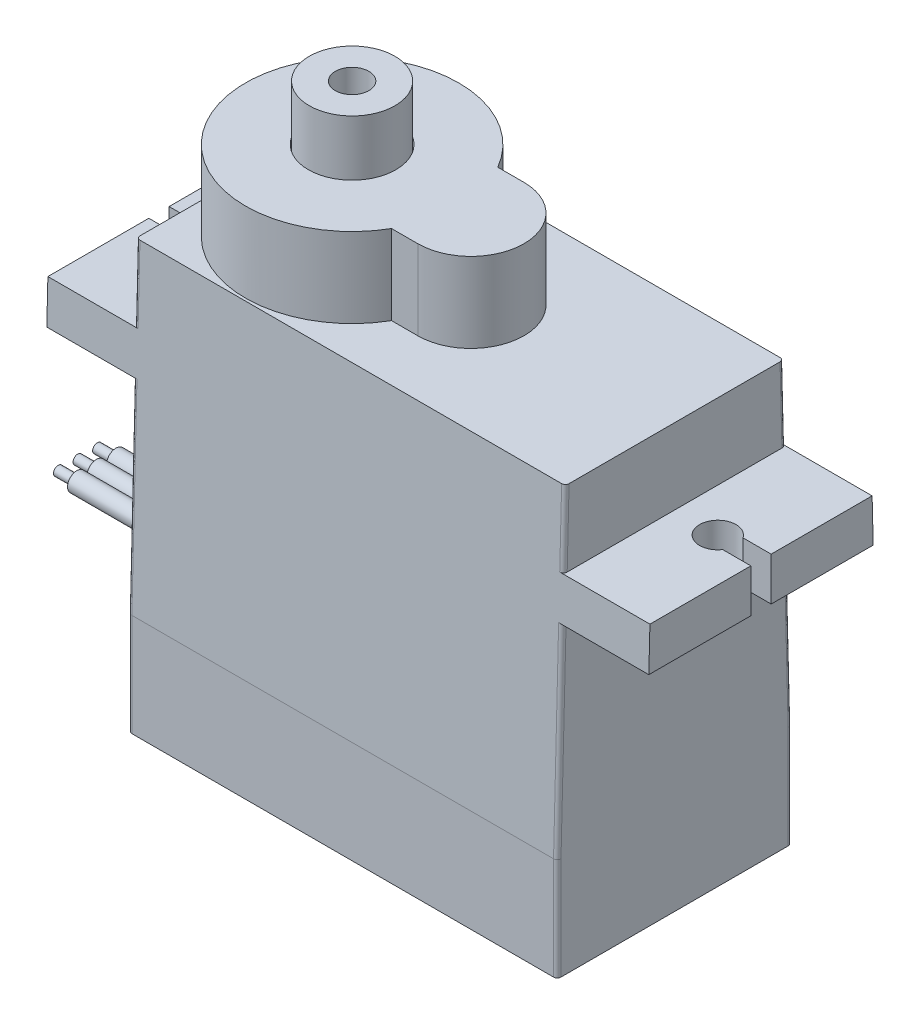
from build123d import *

# Parameters (mm, degrees)
BOSS_EXTRUDE1_DEPTH      = 6.295
BOSS_EXTRUDE2_DEPTH      = 4.28
CUT_EXTRUDE4_DEPTH       = 33.31
SKETCH4_R                = 0.975
SKETCH4_W                = 1.511544683
SKETCH4_H                = 1.09
CUT_EXTRUDE1_DEPTH       = 11.66
SKETCH5_R                = 1
SKETCH5_R_2              = 0.975
CUT_EXTRUDE2_DEPTH       = 1
SKETCH6_R                = 0.5
BOSS_EXTRUDE4_DEPTH      = 8
SKETCH7_R                = 0.25
BOSS_EXTRUDE5_DEPTH      = 1
FILLET1_R                = 0.3
FILLET3_R                = 0.2
SKETCH12_R               = 2.3
SKETCH12_R_2             = 0.9
BOSS_EXTRUDE6_DEPTH      = 2.95
BOSS_EXTRUDE6_DEPTH_BACK = 1
SKETCH13_R               = 2.35
CUT_EXTRUDE5_DEPTH       = 5


with BuildPart() as part:
    # Sketch1 → Boss-Extrude1 (new body, symmetric)
    with BuildSketch(Plane.XY):
        Polygon((-7.13, 6.38), (15.9, 6.38), (15.9, 2.32), (20.54, 2.32), (20.54, 0), (15.9, 0), (15.9, -16.34), (-7.13, -16.34), (-7.13, 0), (-11.77, 0), (-11.77, 2.32), (-7.13, 2.32), align=None)
    extrude(amount=BOSS_EXTRUDE1_DEPTH, both=True)

    # Sketch2 → Boss-Extrude2 (add)
    with BuildSketch(Plane(origin=(0, 6.38, 0), x_dir=(1, 0, 0), z_dir=(0, 1, 0))):
        with BuildLine():
            Line((3.560191336, -2.85), (4.97, -2.85))
            ThreePointArc((4.97, -2.85), (7.82, 0), (4.97, 2.85))
            Line((4.97, 2.85), (3.560191336, 2.85))
            ThreePointArc((3.560191336, 2.85), (-7.13, 0), (3.560191336, -2.85))
        make_face()
    extrude(amount=BOSS_EXTRUDE2_DEPTH)

    # Sketch11 → Cut-Extrude4 (cut, through all)
    with BuildSketch(Plane.ZY.offset(11.77)):
        Polygon((-5.86, 6.38), (-6.295, -10.84), (-6.295, 6.38), align=None)
    cut_extrude4 = extrude(amount=-CUT_EXTRUDE4_DEPTH, mode=Mode.SUBTRACT)

    # Mirror1: Cut-Extrude4 across plane
    add(cut_extrude4.mirror(Plane.XY), mode=Mode.SUBTRACT)

    # Sketch4 → Cut-Extrude1 (cut, through all)
    with BuildSketch(Plane(origin=(0, 0, 0), x_dir=(1, 0, 0), z_dir=(0, 1, 0))):
        with Locations((-9.45, 0)):
            Circle(SKETCH4_R)
        with Locations((-11.014227659, 0)):
            Rectangle(SKETCH4_W, SKETCH4_H)
    cut_extrude1 = extrude(amount=CUT_EXTRUDE1_DEPTH, mode=Mode.SUBTRACT)

    # Mirror2: Cut-Extrude1 across plane
    add(cut_extrude1.mirror(Plane(origin=(4.385, -10.84, 6.295), x_dir=(0, 0, 1), z_dir=(-1, 0, 0))), mode=Mode.SUBTRACT)

    # Sketch5 → Cut-Extrude2 (cut)
    with BuildSketch(Plane.XZ.offset(16.34)):
        with Locations((-5.49, 4.35)):
            Circle(SKETCH5_R)
        with Locations((-5.49, 4.35)):
            Circle(SKETCH5_R_2, mode=Mode.SUBTRACT)
        with Locations((-5.49, -4.35)):
            Circle(SKETCH5_R)
        with Locations((-5.49, -4.35)):
            Circle(SKETCH5_R_2, mode=Mode.SUBTRACT)
        with Locations((14.26, -4.35)):
            Circle(SKETCH5_R)
        with Locations((14.26, -4.35)):
            Circle(SKETCH5_R_2, mode=Mode.SUBTRACT)
        with Locations((14.26, 4.35)):
            Circle(SKETCH5_R)
        with Locations((14.26, 4.35)):
            Circle(SKETCH5_R_2, mode=Mode.SUBTRACT)
    extrude(amount=-CUT_EXTRUDE2_DEPTH, mode=Mode.SUBTRACT)

    # Sketch6 → Boss-Extrude4 (add)
    with BuildSketch(Plane.ZY.offset(7.13)):
        with Locations((0, -11.34)):
            Circle(SKETCH6_R)
        with Locations((1.05, -11.34)):
            Circle(SKETCH6_R)
        with Locations((-1.05, -11.34)):
            Circle(SKETCH6_R)
    extrude(amount=BOSS_EXTRUDE4_DEPTH)

    # Sketch7 → Boss-Extrude5 (add)
    with BuildSketch(Plane.ZY.offset(15.13)):
        with Locations((0, -11.34)):
            Circle(SKETCH7_R)
        with Locations((1.05, -11.34)):
            Circle(SKETCH7_R)
        with Locations((-1.05, -11.34)):
            Circle(SKETCH7_R)
    extrude(amount=BOSS_EXTRUDE5_DEPTH)

    # Fillet1
    fillet1_edges = [part.edges().sort_by_distance(p)[0] for p in [
        (-6.465, -16.34, 4.35),
        (-6.465, -16.34, -4.35),
        (13.285, -16.34, -4.35),
        (13.285, -16.34, 4.35),
    ]]
    fillet(fillet1_edges, radius=FILLET1_R)

    # Fillet3
    fillet3_edges = [part.edges().sort_by_distance(p)[0] for p in [
        (15.9, -13.59, -6.295),
        (15.9, -13.59, 6.295),
        (-7.13, -13.59, -6.295),
        (-7.13, 4.35, -5.911280488),
        (-7.13, -5.42, -6.158083624),
        (15.9, -5.42, -6.158083624),
        (15.9, 4.35, -5.911280488),
        (-7.13, -13.59, 6.295),
        (-7.13, 4.35, 5.911280488),
        (-7.13, -5.42, 6.158083624),
        (15.9, -5.42, 6.158083624),
        (15.9, 4.35, 5.911280488),
    ]]
    fillet(fillet3_edges, radius=FILLET3_R)

    # Sketch13 → Cut-Extrude5 (cut)
    with BuildSketch(Plane(origin=(0, 13.61, 0), x_dir=(1, 0, 0), z_dir=(0, 1, 0))):
        with Locations((-1.405, 0)):
            Circle(SKETCH13_R)
    extrude(amount=-CUT_EXTRUDE5_DEPTH, mode=Mode.SUBTRACT)


with BuildPart() as body_2:
    # Sketch12 → Boss-Extrude6 (new body, two sides)
    with BuildSketch(Plane(origin=(0, 10.66, 0), x_dir=(1, 0, 0), z_dir=(0, 1, 0))) as boss_extrude6_sk:
        with Locations((-1.405, 0)):
            Circle(SKETCH12_R)
        with Locations((-1.405, 0)):
            Circle(SKETCH12_R_2, mode=Mode.SUBTRACT)
    extrude(amount=BOSS_EXTRUDE6_DEPTH)
    extrude(boss_extrude6_sk.sketch, amount=-BOSS_EXTRUDE6_DEPTH_BACK)


solid = Compound([part.part, body_2.part])
